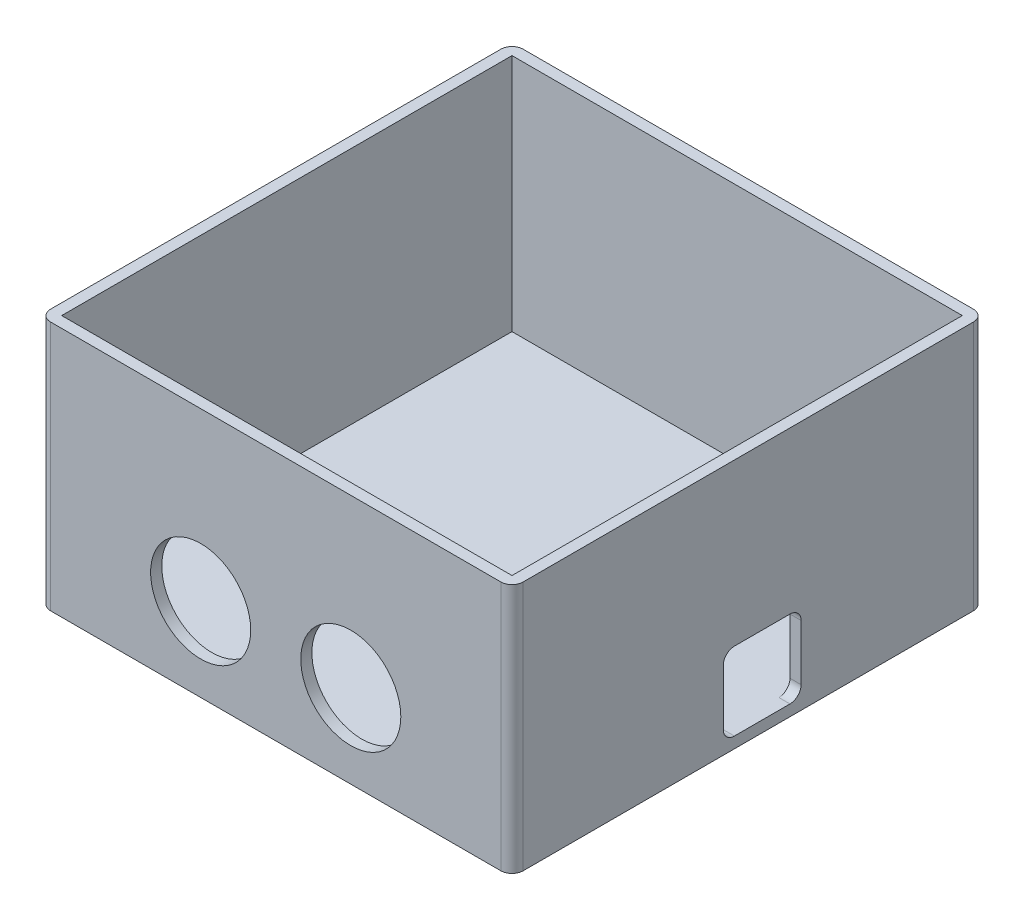
from build123d import *

# Parameters (mm, degrees)
SKETCH1_W           = 85
SKETCH1_H           = 85
BOSS_EXTRUDE1_DEPTH = 2
SKETCH2_W           = 85
SKETCH2_H           = 85
SKETCH2_W_2         = 81
SKETCH2_H_2         = 81
BOSS_EXTRUDE2_DEPTH = 43
SKETCH3_R           = 9
CUT_EXTRUDE1_DEPTH  = 2
SKETCH4_W           = 14
SKETCH4_H           = 14
CUT_EXTRUDE2_DEPTH  = 2
FILLET1_R           = 2


with BuildPart() as part:
    # Sketch1 → Boss-Extrude1 (new body)
    with BuildSketch(Plane(origin=(0, 0, 0), x_dir=(1, 0, 0), z_dir=(0, 1, 0))):
        with Locations((5.537676609, -18.97566719)):
            Rectangle(SKETCH1_W, SKETCH1_H)
    extrude(amount=BOSS_EXTRUDE1_DEPTH)

    # Sketch2 → Boss-Extrude2 (add)
    with BuildSketch(Plane(origin=(0, 2, 0), x_dir=(1, 0, 0), z_dir=(0, 1, 0))):
        with Locations((5.537676609, -18.97566719)):
            Rectangle(SKETCH2_W, SKETCH2_H)
        with Locations((5.537676609, -18.97566719)):
            Rectangle(SKETCH2_W_2, SKETCH2_H_2, mode=Mode.SUBTRACT)
    extrude(amount=BOSS_EXTRUDE2_DEPTH)

    # Sketch3 → Cut-Extrude1 (cut)
    with BuildSketch(Plane.XY.offset(61.47566719)):
        with Locations((-7.962323391, 15)):
            Circle(SKETCH3_R)
        with Locations((19.037676609, 15)):
            Circle(SKETCH3_R)
    extrude(amount=-CUT_EXTRUDE1_DEPTH, mode=Mode.SUBTRACT)

    # Sketch4 → Cut-Extrude2 (cut)
    with BuildSketch(Plane(origin=(48.037676609, 0, 0), x_dir=(0, 0, -1), z_dir=(1, 0, 0))):
        with Locations((-16.47566719, 9)):
            Rectangle(SKETCH4_W, SKETCH4_H)
    extrude(amount=-CUT_EXTRUDE2_DEPTH, mode=Mode.SUBTRACT)

    # Fillet1
    fillet1_edges = [part.edges().sort_by_distance(p)[0] for p in [
        (47.037676609, 2, 23.47566719),
        (47.037676609, 16, 23.47566719),
        (47.037676609, 16, 9.47566719),
        (47.037676609, 2, 9.47566719),
        (-36.962323391, 22.5, -23.52433281),
        (-36.962323391, 22.5, 61.47566719),
        (48.037676609, 22.5, 61.47566719),
        (48.037676609, 22.5, -23.52433281),
    ]]
    fillet(fillet1_edges, radius=FILLET1_R)


solid = part.part
